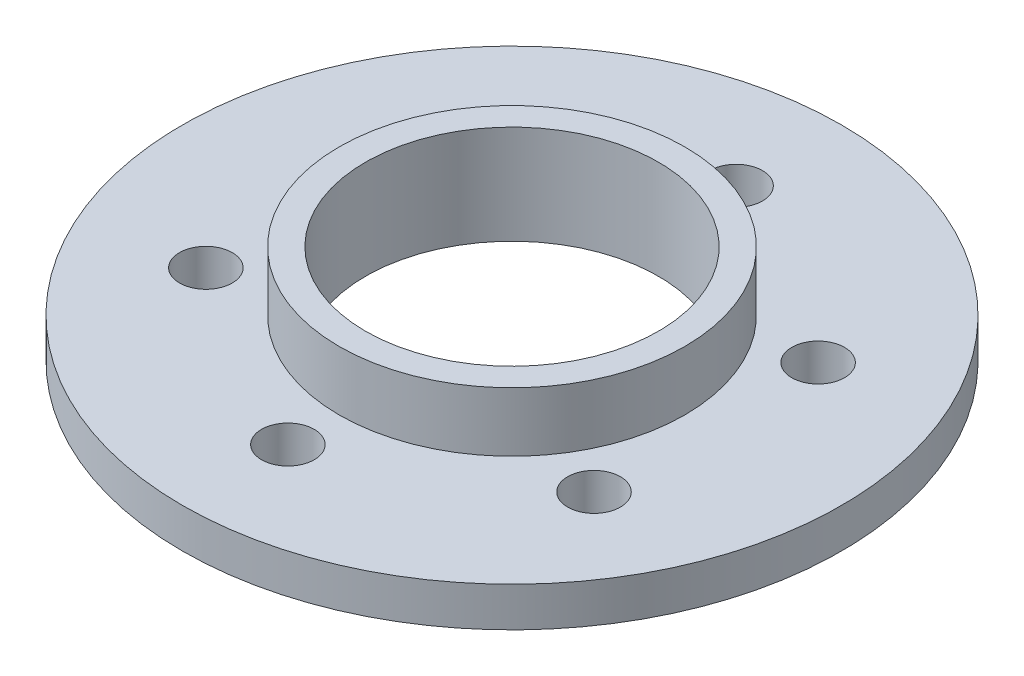
from build123d import *

# Parameters (mm, degrees)
CROQUIS1_R              = 25
CROQUIS1_R_2            = 4.7625
SALIENTE_EXTRUIR1_DEPTH = 3
CROQUIS2_R              = 2
CORTAR_EXTRUIR1_DEPTH   = 36.482389998
CROQUIS3_R              = 13.1125
CROQUIS3_R_2            = 11.1125
SALIENTE_EXTRUIR2_DEPTH = 4.5
CROQUIS3_2_R            = 11.1125
CROQUIS3_2_R_2          = 4.7625
CORTAR_EXTRUIR2_DEPTH   = 36.640566774


with BuildPart() as part:
    # Croquis1 → Saliente-Extruir1 (new body)
    with BuildSketch(Plane(origin=(0, 0, 0), x_dir=(1, 0, 0), z_dir=(0, 1, 0))):
        Circle(CROQUIS1_R)
        Circle(CROQUIS1_R_2, mode=Mode.SUBTRACT)
    extrude(amount=SALIENTE_EXTRUIR1_DEPTH)

    # Croquis2 → Cortar-Extruir1 (cut, through all)
    with BuildSketch(Plane(origin=(0, 3, 0), x_dir=(1, 0, 0), z_dir=(0, 1, 0))):
        with Locations((0, 17)):
            Circle(CROQUIS2_R)
        with Locations((14.722431864, 8.5)):
            Circle(CROQUIS2_R)
        with Locations((14.722431864, -8.5)):
            Circle(CROQUIS2_R)
        with Locations((0, -17)):
            Circle(CROQUIS2_R)
        with Locations((-14.722431864, -8.5)):
            Circle(CROQUIS2_R)
        with Locations((-14.722431864, 8.5)):
            Circle(CROQUIS2_R)
    extrude(amount=-CORTAR_EXTRUIR1_DEPTH, mode=Mode.SUBTRACT)

    # Croquis3 → Saliente-Extruir2 (add)
    with BuildSketch(Plane(origin=(0, 3, 0), x_dir=(1, 0, 0), z_dir=(0, 1, 0))):
        Circle(CROQUIS3_R)
        Circle(CROQUIS3_R_2, mode=Mode.SUBTRACT)
    extrude(amount=SALIENTE_EXTRUIR2_DEPTH)

    # Croquis3_2 → Cortar-Extruir2 (cut, through all)
    with BuildSketch(Plane(origin=(0, 3, 0), x_dir=(1, 0, 0), z_dir=(0, 1, 0))):
        Circle(CROQUIS3_2_R)
        Circle(CROQUIS3_2_R_2, mode=Mode.SUBTRACT)
    extrude(amount=-CORTAR_EXTRUIR2_DEPTH, mode=Mode.SUBTRACT)


solid = part.part
